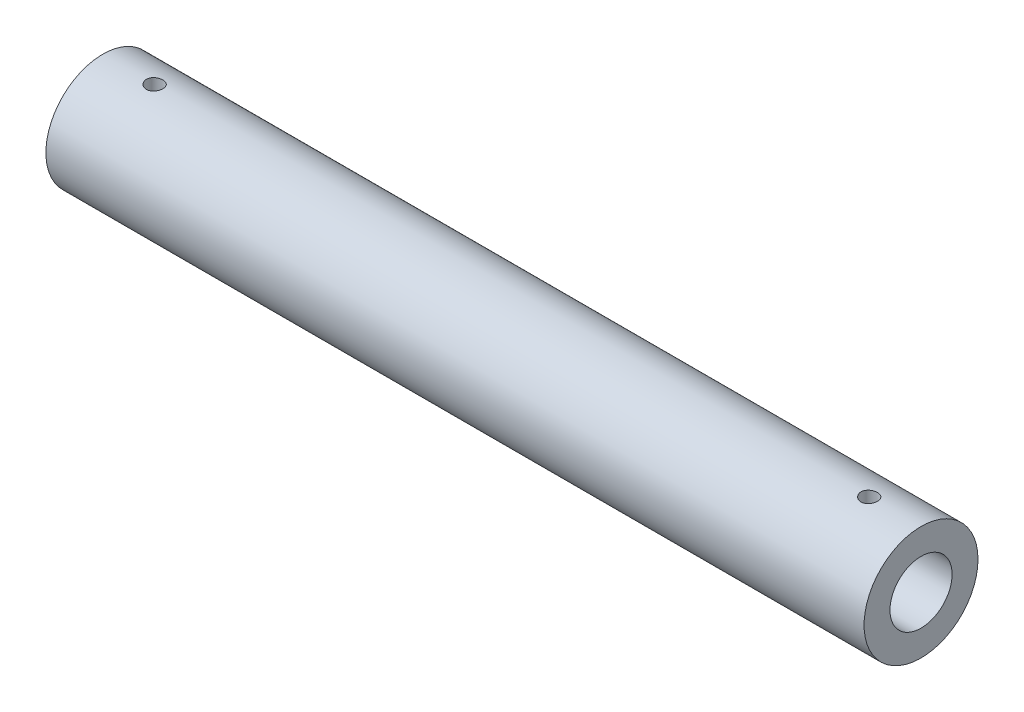
from build123d import *

# Parameters (mm, degrees)
SKETCH2_R               = 11
SKETCH2_R_2             = 6
BOSS_EXTRUDE1_DEPTH     = 157.975
SKETCH3_R               = 1.5875
CUT_EXTRUDE1_DEPTH      = 12
CUT_EXTRUDE1_DEPTH_BACK = 12


with BuildPart() as part:
    # Sketch2 → Boss-Extrude1 (new body)
    with BuildSketch(Plane(origin=(0, 0, 0), x_dir=(0, 0, -1), z_dir=(1, 0, 0))):
        Circle(SKETCH2_R)
        Circle(SKETCH2_R_2, mode=Mode.SUBTRACT)
    extrude(amount=BOSS_EXTRUDE1_DEPTH)

    # Sketch3 → Cut-Extrude1 (cut, two sides)
    with BuildSketch(Plane(origin=(0, 0, 0), x_dir=(1, 0, 0), z_dir=(0, 1, 0))) as cut_extrude1_sk:
        with Locations((10, 0)):
            Circle(SKETCH3_R)
        with Locations((147.975, 0)):
            Circle(SKETCH3_R)
    extrude(amount=CUT_EXTRUDE1_DEPTH, mode=Mode.SUBTRACT)
    extrude(cut_extrude1_sk.sketch, amount=-CUT_EXTRUDE1_DEPTH_BACK, mode=Mode.SUBTRACT)


solid = part.part
